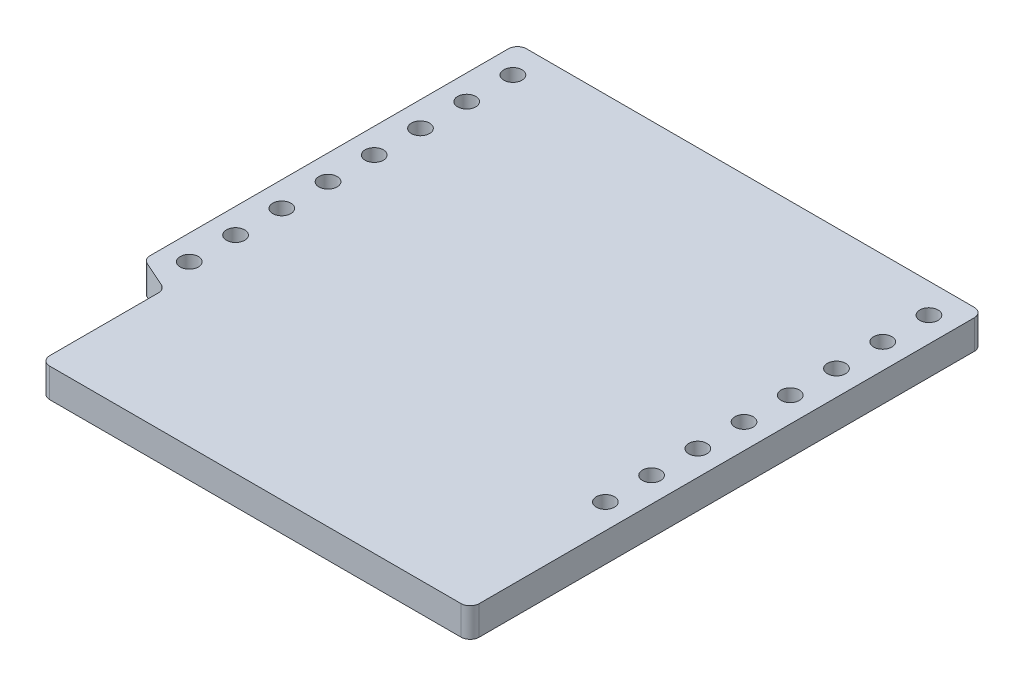
from build123d import *

# Parameters (mm, degrees)
SKETCH2_R           = 0.5
BOSS_EXTRUDE1_DEPTH = 1.6
FILLET1_R           = 0.5


with BuildPart() as part:
    # Sketch2 → Boss-Extrude1 (new body)
    with BuildSketch(Plane(origin=(0, 0, 0), x_dir=(1, 0, 0), z_dir=(0, 1, 0))):
        Polygon((-12.8, 7.690457371), (-12.8, 28.2), (12.8, 28.2), (12.8, 0), (-10.8, 0), (-10.8, 6.8), align=None)
        with Locations((-11.43, 26.58)):
            Circle(SKETCH2_R, mode=Mode.SUBTRACT)
        with Locations((11.43, 26.58)):
            Circle(SKETCH2_R, mode=Mode.SUBTRACT)
        with Locations((-11.43, 24.04)):
            Circle(SKETCH2_R, mode=Mode.SUBTRACT)
        with Locations((11.43, 24.04)):
            Circle(SKETCH2_R, mode=Mode.SUBTRACT)
        with Locations((-11.43, 21.5)):
            Circle(SKETCH2_R, mode=Mode.SUBTRACT)
        with Locations((11.43, 21.5)):
            Circle(SKETCH2_R, mode=Mode.SUBTRACT)
        with Locations((-11.43, 18.96)):
            Circle(SKETCH2_R, mode=Mode.SUBTRACT)
        with Locations((11.43, 18.96)):
            Circle(SKETCH2_R, mode=Mode.SUBTRACT)
        with Locations((-11.43, 16.42)):
            Circle(SKETCH2_R, mode=Mode.SUBTRACT)
        with Locations((11.43, 16.42)):
            Circle(SKETCH2_R, mode=Mode.SUBTRACT)
        with Locations((-11.43, 13.88)):
            Circle(SKETCH2_R, mode=Mode.SUBTRACT)
        with Locations((11.43, 13.88)):
            Circle(SKETCH2_R, mode=Mode.SUBTRACT)
        with Locations((-11.43, 11.34)):
            Circle(SKETCH2_R, mode=Mode.SUBTRACT)
        with Locations((11.43, 11.34)):
            Circle(SKETCH2_R, mode=Mode.SUBTRACT)
        with Locations((-11.43, 8.8)):
            Circle(SKETCH2_R, mode=Mode.SUBTRACT)
        with Locations((11.43, 8.8)):
            Circle(SKETCH2_R, mode=Mode.SUBTRACT)
    extrude(amount=BOSS_EXTRUDE1_DEPTH)

    # Fillet1
    fillet1_edges = [part.edges().sort_by_distance(p)[0] for p in [
        (-10.8, 0.8, 0),
        (-10.8, 0.8, -6.8),
        (-12.8, 0.8, -7.690457371),
        (-12.8, 0.8, -28.2),
        (12.8, 0.8, -28.2),
        (12.8, 0.8, 0),
    ]]
    fillet(fillet1_edges, radius=FILLET1_R)


solid = part.part
